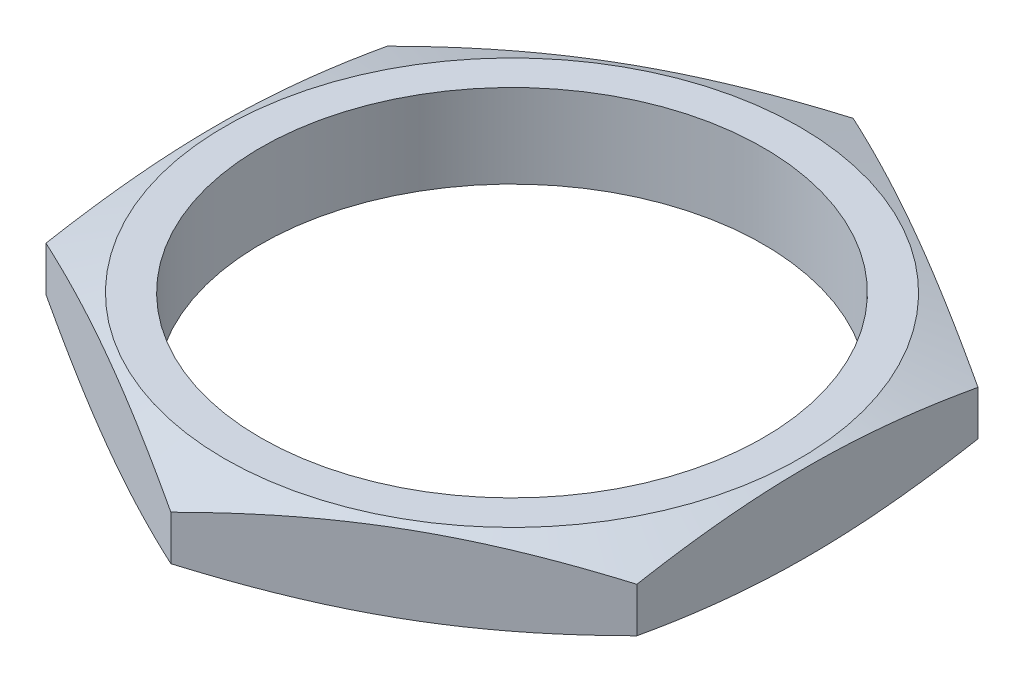
from build123d import *

# Parameters (mm, degrees)
SKETCH1_R           = 5.953125
BOSS_EXTRUDE1_DEPTH = 1.9812


with BuildPart() as part:
    # Sketch1 → Boss-Extrude1 (new body)
    with BuildSketch(Plane(origin=(0, 0, 0), x_dir=(1, 0, 0), z_dir=(0, 1, 0))):
        Polygon((0, -8.080247957), (6.9977, -4.040123979), (6.9977, 4.040123979), (0, 8.080247957), (-6.9977, 4.040123979), (-6.9977, -4.040123979), align=None)
        Circle(SKETCH1_R, mode=Mode.SUBTRACT)
    extrude(amount=BOSS_EXTRUDE1_DEPTH)

    # Sketch2 → Cut-Revolve1 (revolve, cut)
    with BuildSketch(Plane(origin=(0, 0, 0), x_dir=(0, 0, -1), z_dir=(1, 0, 0))):
        Polygon((-8.080247957, 1.518957802), (-6.810247957, 1.9812), (-8.080247957, 1.9812), align=None)
        Polygon((-8.080247957, 0), (-8.080247957, 0.462242198), (-6.810247957, 0), align=None)
    revolve(axis=Axis((0, 0, 0), (0, 1, 0)), mode=Mode.SUBTRACT)


solid = part.part
